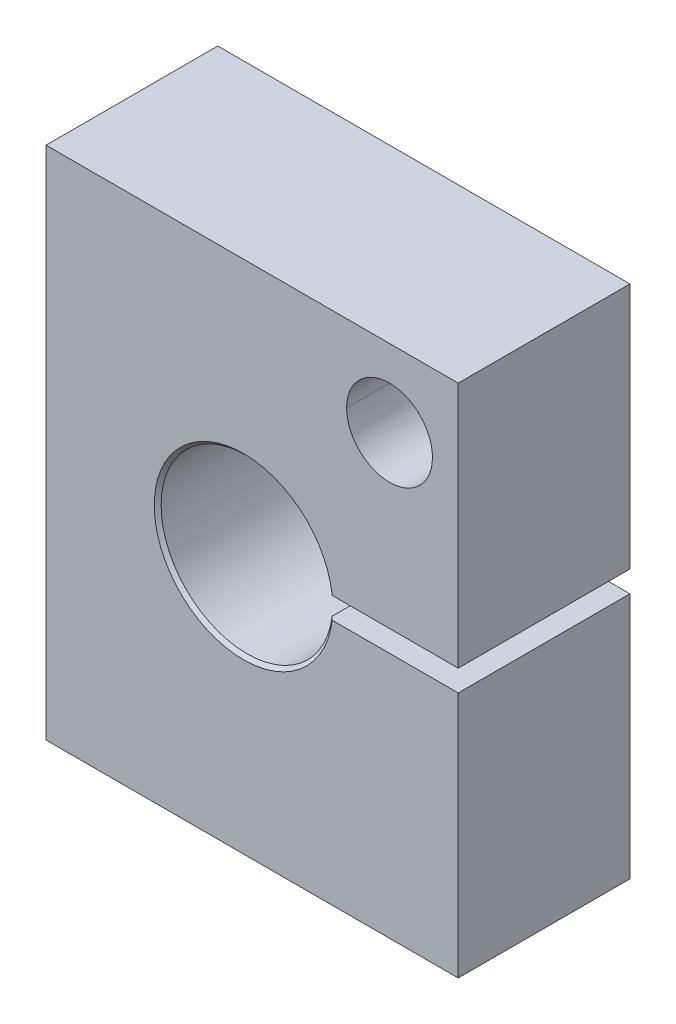
from build123d import *

# Parameters (mm, degrees)
SKETCH1_W           = 30.48
SKETCH1_H           = 38.1
BOSS_EXTRUDE1_DEPTH = 6.35
CUT_EXTRUDE2_DEPTH  = 13.7
CHAMFER1_SIZE       = 0.254
SKETCH8_R           = 3.175
CUT_EXTRUDE4_DEPTH  = 13.7


with BuildPart() as part:
    # Sketch1 → Boss-Extrude1 (new body, symmetric)
    with BuildSketch(Plane.XY):
        Rectangle(SKETCH1_W, SKETCH1_H)
    extrude(amount=BOSS_EXTRUDE1_DEPTH, both=True)

    # Sketch2 → Cut-Extrude2 (cut, through all)
    with BuildSketch(Plane.XY.offset(6.35)):
        with BuildLine():
            Line((97.980767498, 0.79375), (15.24, 0.79375))
            Line((15.24, 0.79375), (5.665195309, 0.79375))
            ThreePointArc((5.665195309, 0.79375), (-6.985, 0), (5.665195309, -0.79375))
            Line((5.665195309, -0.79375), (15.24, -0.79375))
            Line((15.24, -0.79375), (97.980767498, -0.79375))
            Line((97.980767498, -0.79375), (263.462302495, -0.79375))
            Line((263.462302495, -0.79375), (263.462302495, 0.79375))
            Line((263.462302495, 0.79375), (97.980767498, 0.79375))
        make_face()
    extrude(amount=-CUT_EXTRUDE2_DEPTH, mode=Mode.SUBTRACT)

    # Sketch6 → 1/4 (0.25) Diameter Hole1 (revolve, cut)
    with BuildSketch(Plane(origin=(8.89, -19.05, 0), x_dir=(0, 0, -1), z_dir=(1, 0, 0))):
        Polygon((0, 0), (0, 9.527732465), (3.175, 7.62), (3.175, 0), align=None)
    f_1_4_0_25_diameter_hole1 = revolve(axis=Axis((8.89, -25.4, 0), (0, 1, 0)), mode=Mode.SUBTRACT)

    # Chamfer1
    chamfer1_edges = [part.edges().sort_by_distance(p)[0] for p in [
        (-6.985, 0, -6.35),
        (-6.985, 0, 6.35),
    ]]
    chamfer(chamfer1_edges, length=CHAMFER1_SIZE)

    # Mirror1: 1/4 (0.25) Diameter Hole1 across plane
    add(f_1_4_0_25_diameter_hole1.mirror(Plane(origin=(0, 0, 0), x_dir=(0, 0, 1), z_dir=(1, 0, 0))), mode=Mode.SUBTRACT)

    # Sketch8 → Cut-Extrude4 (cut, through all)
    with BuildSketch(Plane.XY.offset(6.35)):
        with Locations((10.16, 13.335)):
            Circle(SKETCH8_R)
    extrude(amount=-CUT_EXTRUDE4_DEPTH, mode=Mode.SUBTRACT)


solid = part.part
